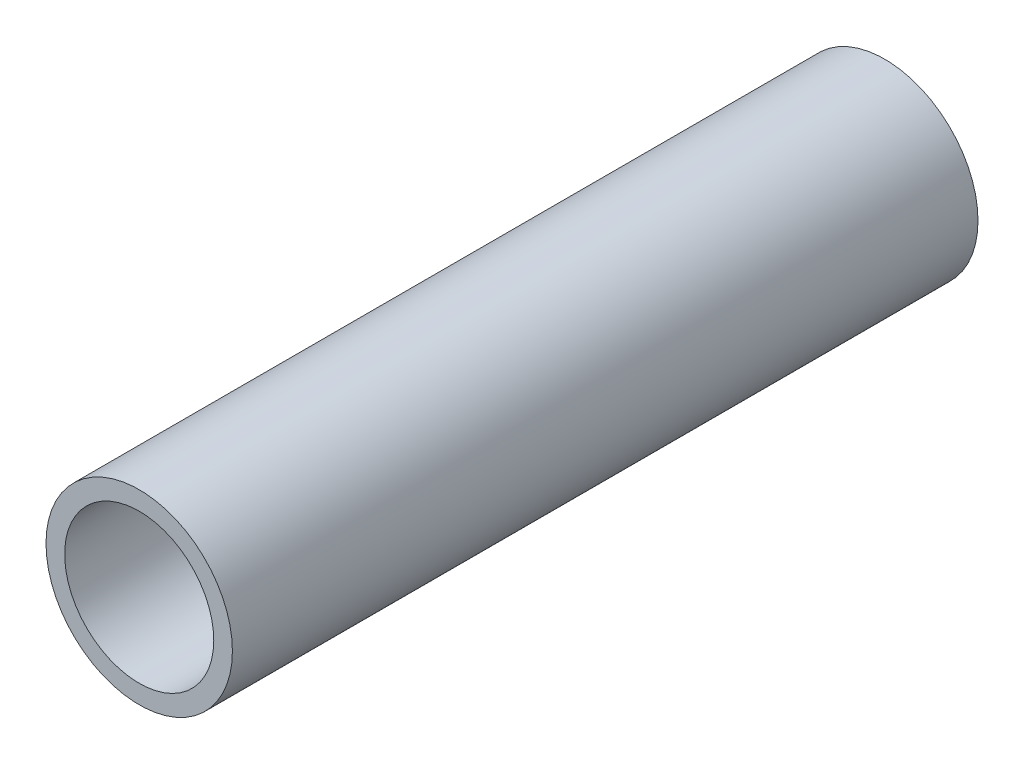
from build123d import *

# Parameters (mm, degrees)
SKETCH_1_R      = 2.5
SKETCH_1_R_2    = 2
EXTRUDE_1_DEPTH = 20


with BuildPart() as part:
    # ｽｹｯﾁ1 → ﾎﾞｽ - 押し出し1 (new body)
    with BuildSketch(Plane.XY):
        Circle(SKETCH_1_R)
        Circle(SKETCH_1_R_2, mode=Mode.SUBTRACT)
    extrude(amount=EXTRUDE_1_DEPTH)


solid = part.part
